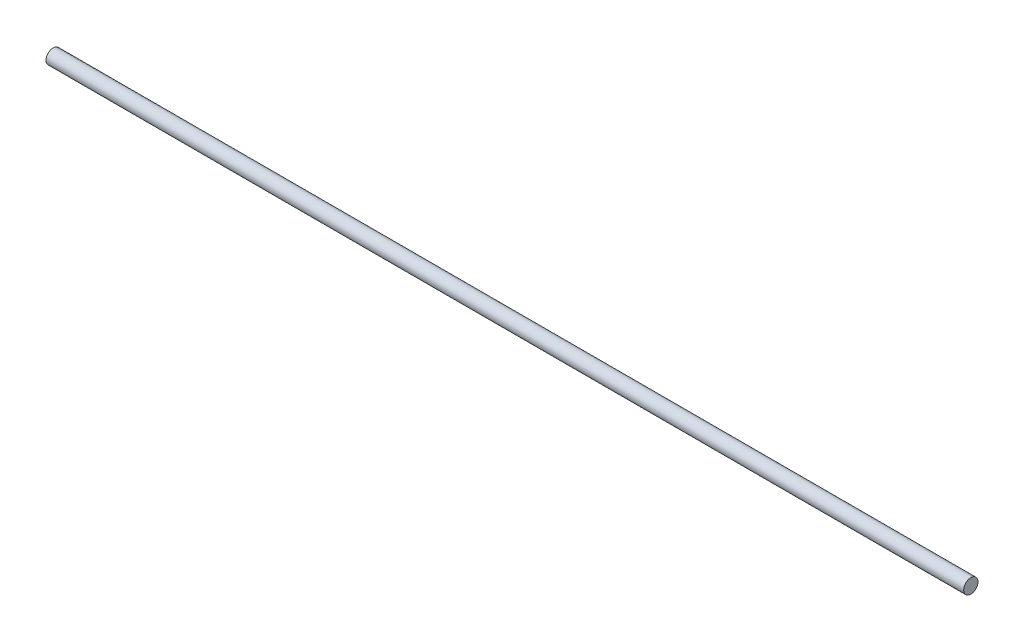
from build123d import *

# Parameters (mm, degrees)
SKETCH1_R           = 3.175
BOSS_EXTRUDE1_DEPTH = 406.4


with BuildPart() as part:
    # Sketch1 → Boss-Extrude1 (new body)
    with BuildSketch(Plane(origin=(0, 0, 0), x_dir=(0, 0, -1), z_dir=(1, 0, 0))):
        Circle(SKETCH1_R)
    extrude(amount=BOSS_EXTRUDE1_DEPTH)


solid = part.part
